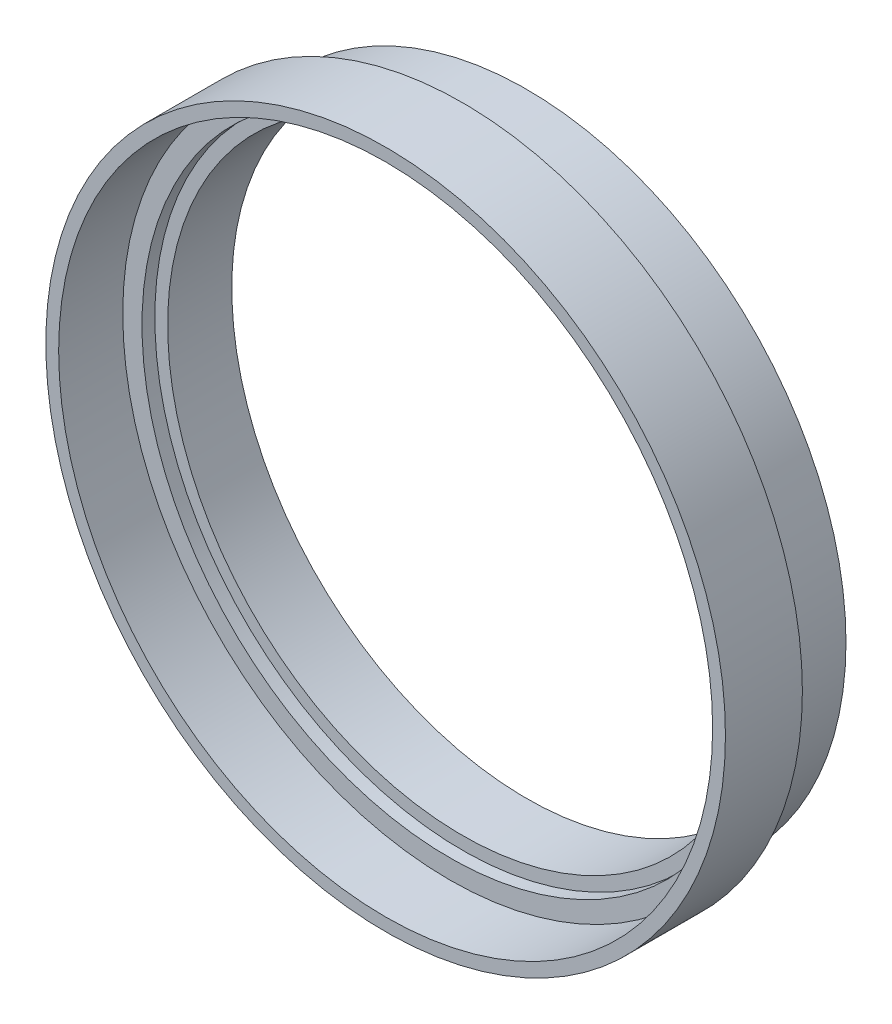
from build123d import *

# Parameters (mm, degrees)
SKETCH_1_R      = 24.9
SKETCH_1_R_2    = 23
EXTRUDE_1_DEPTH = 5
SKETCH_2_R      = 26.5
SKETCH_2_R_2    = 24
EXTRUDE_2_DEPTH = 1
SKETCH_3_R      = 26.5
SKETCH_3_R_2    = 25.5
EXTRUDE_3_DEPTH = 5


with BuildPart() as part:
    # 草图1 → 凸台-拉伸1 (new body)
    with BuildSketch(Plane.XY):
        Circle(SKETCH_1_R)
        Circle(SKETCH_1_R_2, mode=Mode.SUBTRACT)
    extrude(amount=EXTRUDE_1_DEPTH)

    # 草图2 → 凸台-拉伸2 (add)
    with BuildSketch(Plane.XY.offset(5)):
        Circle(SKETCH_2_R)
        Circle(SKETCH_2_R_2, mode=Mode.SUBTRACT)
    extrude(amount=EXTRUDE_2_DEPTH)

    # 草图3 → 凸台-拉伸3 (add)
    with BuildSketch(Plane.XY.offset(6)):
        Circle(SKETCH_3_R)
        Circle(SKETCH_3_R_2, mode=Mode.SUBTRACT)
    extrude(amount=EXTRUDE_3_DEPTH)


solid = part.part
